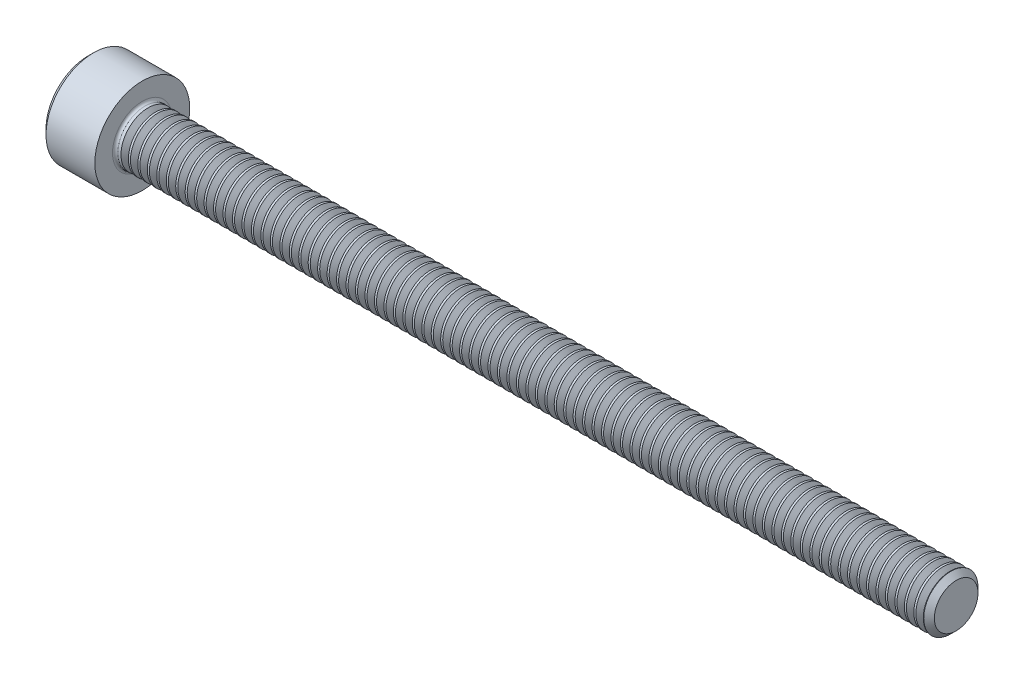
from build123d import *

# Parameters (mm, degrees)
FILLET1_R       = 0.2
HEX_2_DEPTH     = 2
THDSCHPAT_COUNT = 85
THDSCHPAT_PITCH = 0.697647059


with BuildPart() as part:
    # BodySke → Base-Revolve (revolve)
    with BuildSketch(Plane.XY):
        Polygon((0, 0), (0, 3.1), (0.4, 3.5), (4, 3.5), (4, 2), (63.61, 2), (64, 1.61), (64, 0), align=None)
    revolve(axis=Axis((-31.75, 0, 0), (1, 0, 0)))

    # Fillet1
    fillet1_edges = [part.edges().sort_by_distance(p)[0] for p in [
        (4, -2, 0),
    ]]
    fillet(fillet1_edges, radius=FILLET1_R)

    # Sketch2 → Hex-PreBroach (revolve, cut)
    with BuildSketch(Plane.XY):
        Polygon((0, 1.5355), (2, 1.5355), (2.886521338, 0), (0, 0), align=None)
    revolve(axis=Axis((0, 0, 0), (1, 0, 0)), mode=Mode.SUBTRACT)

    # Sketch3 → Hex 2 (cut)
    with BuildSketch(Plane(origin=(0, 0, 0), x_dir=(0, 0.5, 0.866025404), z_dir=(-1, 0, 0))):
        Polygon((0.886521338, 1.5355), (-0.886521338, 1.5355), (-1.773042677, 0), (-0.886521338, -1.5355), (0.886521338, -1.5355), (1.773042677, 0), align=None)
    extrude(amount=-HEX_2_DEPTH, mode=Mode.SUBTRACT)

    # ThdSchSke → ThreadSchematic (revolve, cut)
    with BuildSketch(Plane.XY):
        Polygon((4.7, -1.61), (4.42691906, -2), (4.42691906, -2.5), (4.97308094, -2.5), (4.97308094, -2), align=None)
    threadschematic = revolve(axis=Axis((-3.175, 0, 0), (1, 0, 0)), mode=Mode.SUBTRACT)

    # ThdSchPat: ThreadSchematic ×85
    with Locations(*[(i * THDSCHPAT_PITCH, 0, 0) for i in range(1, THDSCHPAT_COUNT)]):
        add(threadschematic, mode=Mode.SUBTRACT)


solid = part.part
